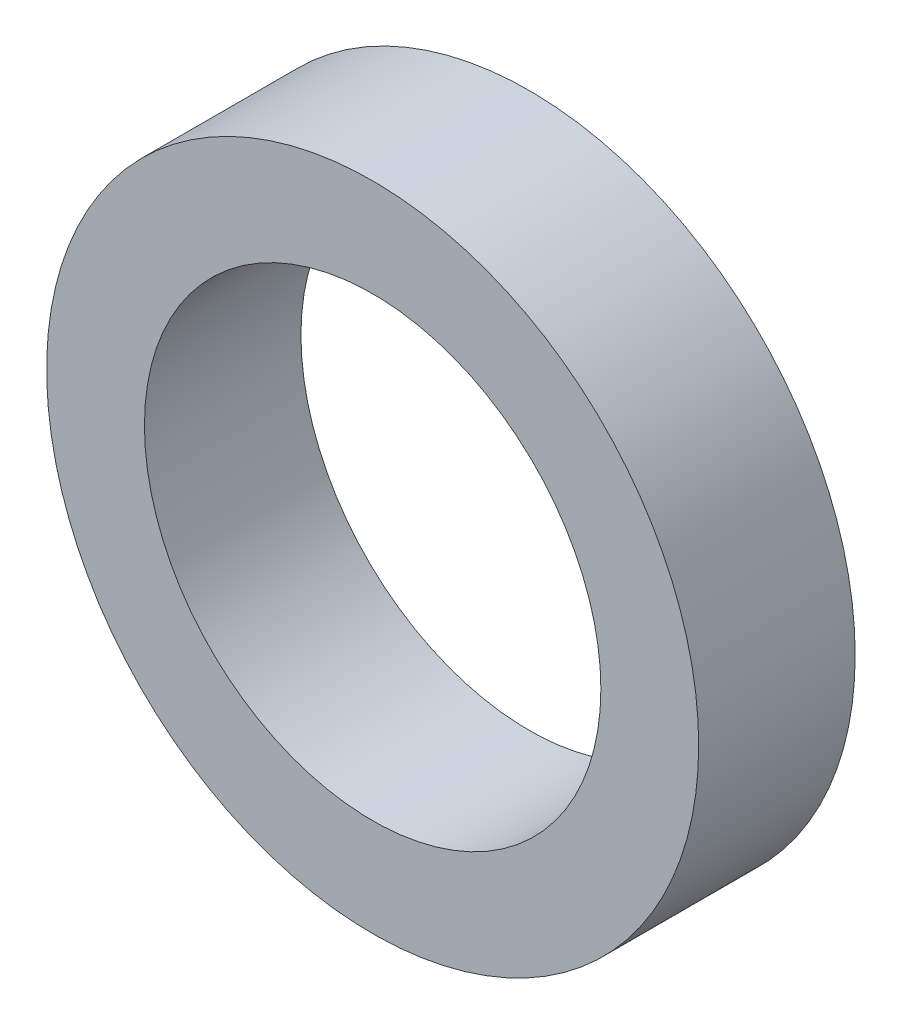
from build123d import *

# Parameters (mm, degrees)
SKETCH_1_R      = 12.5
SKETCH_1_R_2    = 8.75
EXTRUDE_1_DEPTH = 6


with BuildPart() as part:
    # Эскиз1 → Вытянуть1 (new body)
    with BuildSketch(Plane.XY):
        Circle(SKETCH_1_R)
        Circle(SKETCH_1_R_2, mode=Mode.SUBTRACT)
    extrude(amount=-EXTRUDE_1_DEPTH)


solid = part.part
